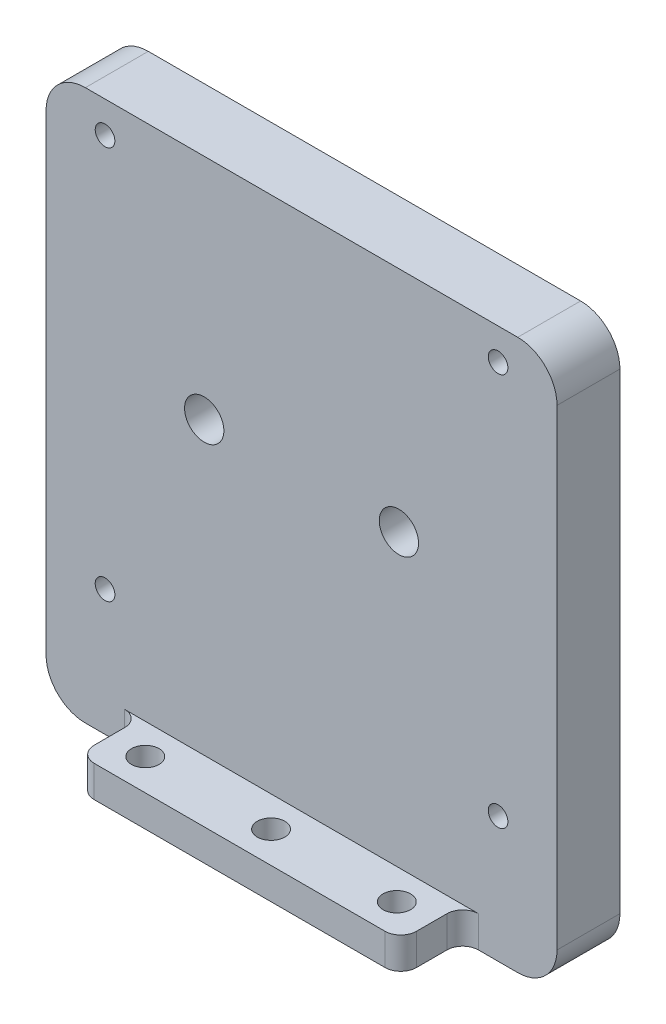
from build123d import *

# Parameters (mm, degrees)
SKETCH1_W                   = 65
SKETCH1_H                   = 70
BOSS_EXTRUDE1_DEPTH         = 8
FILLET1_R                   = 5
SKETCH2_W                   = 41
SKETCH2_H                   = 4
BOSS_EXTRUDE2_DEPTH         = 7.87989528
FILLET2_R                   = 2
SKETCH_1_R                  = 1.75
CUT_EXTRUDE_1_DEPTH         = 71
HOLE_WIZARD_M3_1_D          = 2.5
HOLE_WIZARD_M3_1_DEPTH      = 10
HOLE_WIZARD_M3_1_TIP        = 0.751075774
SKETCH_11_W                 = 65
SKETCH_11_H                 = 70.4
EXTRUDE_1_DEPTH             = 2.9
FILLET_2_R                  = 5
FILLET_3_R                  = 5
FILLET_4_R                  = 5
FILLET_5_R                  = 5
SKETCH_24_W                 = 1.25
SKETCH_24_H                 = 2.901
HOLE_WIZARD_M3_2_AT_2_COUNT = 2
HOLE_WIZARD_M3_2_AT_2_PITCH = 50
HOLE_WIZARD_M3_2_AT_3_COUNT = 2
HOLE_WIZARD_M3_2_AT_3_PITCH = 50
HOLE_WIZARD_M3_2_AT_4_COUNT = 2
HOLE_WIZARD_M3_2_AT_4_PITCH = 70.710678119
HOLE_WIZARD_M4_2_AT_2_COUNT = 2
HOLE_WIZARD_M4_2_AT_2_PITCH = 17.145
HOLE_WIZARD_M4_2_AT_3_COUNT = 2
HOLE_WIZARD_M4_2_AT_3_PITCH = 34.29
HOLE_WIZARD_M4_2_AT_4_COUNT = 2
HOLE_WIZARD_M4_2_AT_4_PITCH = 29.696011096
SKETCH_28_W                 = 16.34592277
SKETCH_28_H                 = 84.825432557
CUT_EXTRUDE_4_DEPTH         = 66
HOLE_WIZARD_M6_1_D          = 5


with BuildPart() as part:
    # Sketch1 → Boss-Extrude1 (new body)
    with BuildSketch(Plane.XY):
        Rectangle(SKETCH1_W, SKETCH1_H)
    extrude(amount=BOSS_EXTRUDE1_DEPTH)

    # Fillet1
    fillet1_edges = [part.edges().sort_by_distance(p)[0] for p in [
        (32.5, -35, 4),
        (-32.5, -35, 4),
        (-32.5, 35, 4),
        (32.5, 35, 4),
    ]]
    fillet(fillet1_edges, radius=FILLET1_R)

    # Sketch2 → Boss-Extrude2 (add)
    with BuildSketch(Plane.XY.offset(8)):
        with Locations((0, -33)):
            Rectangle(SKETCH2_W, SKETCH2_H)
    extrude(amount=BOSS_EXTRUDE2_DEPTH)

    # Fillet2
    fillet2_edges = [part.edges().sort_by_distance(p)[0] for p in [
        (-20.5, -33, 8),
        (20.5, -33, 8),
        (-20.5, -33, 15.87989528),
        (20.5, -33, 15.87989528),
    ]]
    fillet(fillet2_edges, radius=FILLET2_R)

    # 草图1 → 切除-拉伸1 (cut, through all)
    with BuildSketch(Plane.XZ.offset(35)):
        with Locations((-16, 11.87989528)):
            Circle(SKETCH_1_R)
        with Locations((0, 11.87989528)):
            Circle(SKETCH_1_R)
        with Locations((16, 11.87989528)):
            Circle(SKETCH_1_R)
    extrude(amount=-CUT_EXTRUDE_1_DEPTH, mode=Mode.SUBTRACT)

    # M3 螺纹孔1
    with Locations(Plane(origin=(25, -19, 0), x_dir=(-1, 0, 0), z_dir=(0, 0, -1))):
        with Locations((0, 0), (0, 50), (50, 50), (50, 0)):
            Hole(HOLE_WIZARD_M3_1_D / 2, depth=HOLE_WIZARD_M3_1_DEPTH)
            with Locations((0, 0, -(HOLE_WIZARD_M3_1_DEPTH + HOLE_WIZARD_M3_1_TIP / 2))):  # 118° drill point
                Cone(0, HOLE_WIZARD_M3_1_D / 2, HOLE_WIZARD_M3_1_TIP, mode=Mode.SUBTRACT)

    # M6 螺纹孔1 (through all)
    with Locations(Plane(origin=(12.3825, 6, 0), x_dir=(-1, 0, 0), z_dir=(0, 0, -1))):
        with Locations((0, 0), (24.765, 0)):
            Hole(HOLE_WIZARD_M6_1_D / 2)


with BuildPart() as body_2:
    # 草图11 → 凸台-拉伸1 (new body)
    with BuildSketch(Plane(origin=(0, 0, -30.31), x_dir=(-1, 0, 0), z_dir=(0, 0, -1))):
        with Locations((0, 0.2)):
            Rectangle(SKETCH_11_W, SKETCH_11_H)
    extrude(amount=-EXTRUDE_1_DEPTH)

    # 圆角2
    fillet_2_edges = [body_2.edges().sort_by_distance(p)[0] for p in [
        (-32.5, 35.4, -28.86),
    ]]
    fillet(fillet_2_edges, radius=FILLET_2_R)

    # 圆角3
    fillet_3_edges = [body_2.edges().sort_by_distance(p)[0] for p in [
        (-32.5, -35, -28.86),
    ]]
    fillet(fillet_3_edges, radius=FILLET_3_R)

    # 圆角4
    fillet_4_edges = [body_2.edges().sort_by_distance(p)[0] for p in [
        (32.5, -35, -28.86),
    ]]
    fillet(fillet_4_edges, radius=FILLET_4_R)

    # 圆角5
    fillet_5_edges = [body_2.edges().sort_by_distance(p)[0] for p in [
        (32.5, 35.4, -28.86),
    ]]
    fillet(fillet_5_edges, radius=FILLET_5_R)

    # 草图24 → M3 螺纹孔2 (revolve, cut)
    with BuildSketch(Plane(origin=(25, 31, -30.31), x_dir=(0, 1, 0), z_dir=(1, 0, 0))):
        with Locations((0.625, 1.4505)):
            Rectangle(SKETCH_24_W, SKETCH_24_H)
    hole_wizard_m3_2 = revolve(axis=Axis((25, 31, -36.66), (0, 0, 1)), mode=Mode.SUBTRACT)

    # M3 螺纹孔2 at 2: M3 螺纹孔2 ×2
    with Locations(*[(-i * HOLE_WIZARD_M3_2_AT_2_PITCH, 0, 0) for i in range(1, HOLE_WIZARD_M3_2_AT_2_COUNT)]):
        add(hole_wizard_m3_2, mode=Mode.SUBTRACT)

    # M3 螺纹孔2 at 3: M3 螺纹孔2 ×2
    with Locations(*[(0, -i * HOLE_WIZARD_M3_2_AT_3_PITCH, 0) for i in range(1, HOLE_WIZARD_M3_2_AT_3_COUNT)]):
        add(hole_wizard_m3_2, mode=Mode.SUBTRACT)

    # M3 螺纹孔2 at 4: M3 螺纹孔2 ×2
    with Locations(*[Vector(-0.707106781, -0.707106781, 0) * (i * HOLE_WIZARD_M3_2_AT_4_PITCH) for i in range(1, HOLE_WIZARD_M3_2_AT_4_COUNT)]):
        add(hole_wizard_m3_2, mode=Mode.SUBTRACT)

    # 草图27 → M4 六角凹头螺钉的柱形沉头孔2 (revolve, cut)
    with BuildSketch(Plane(origin=(9.41775, -9.820005548, -30.31), x_dir=(0, 1, 0), z_dir=(1, 0, 0))):
        Polygon((0, 0), (0, 38.31), (2.25, 38.31), (2.25, 1.5), (4, 1.5), (4, 0), align=None)
    hole_wizard_m4_2 = revolve(axis=Axis((9.41775, -9.820005548, -36.66), (0, 0, 1)), mode=Mode.SUBTRACT)

    # M4 六角凹头螺钉的柱形沉头孔2 at 2: M4 六角凹头螺钉的柱形沉头孔2 ×2
    with Locations(*[(-i * HOLE_WIZARD_M4_2_AT_2_PITCH, 0, 0) for i in range(1, HOLE_WIZARD_M4_2_AT_2_COUNT)]):
        add(hole_wizard_m4_2, mode=Mode.SUBTRACT)

    # M4 六角凹头螺钉的柱形沉头孔2 at 3: M4 六角凹头螺钉的柱形沉头孔2 ×2
    with Locations(*[Vector(-0.5, 0.866025404, 0) * (i * HOLE_WIZARD_M4_2_AT_3_PITCH) for i in range(1, HOLE_WIZARD_M4_2_AT_3_COUNT)]):
        add(hole_wizard_m4_2, mode=Mode.SUBTRACT)

    # M4 六角凹头螺钉的柱形沉头孔2 at 4: M4 六角凹头螺钉的柱形沉头孔2 ×2
    with Locations(*[(0, i * HOLE_WIZARD_M4_2_AT_4_PITCH, 0) for i in range(1, HOLE_WIZARD_M4_2_AT_4_COUNT)]):
        add(hole_wizard_m4_2, mode=Mode.SUBTRACT)

    # 草图28 → 切除-拉伸4 (cut, through all)
    with BuildSketch(Plane(origin=(32.5, 0, 0), x_dir=(0, 0, -1), z_dir=(1, 0, 0))):
        with Locations((29.455626585, -1.857491224)):
            Rectangle(SKETCH_28_W, SKETCH_28_H)
    extrude(amount=-CUT_EXTRUDE_4_DEPTH, mode=Mode.SUBTRACT)


solid = part.part
